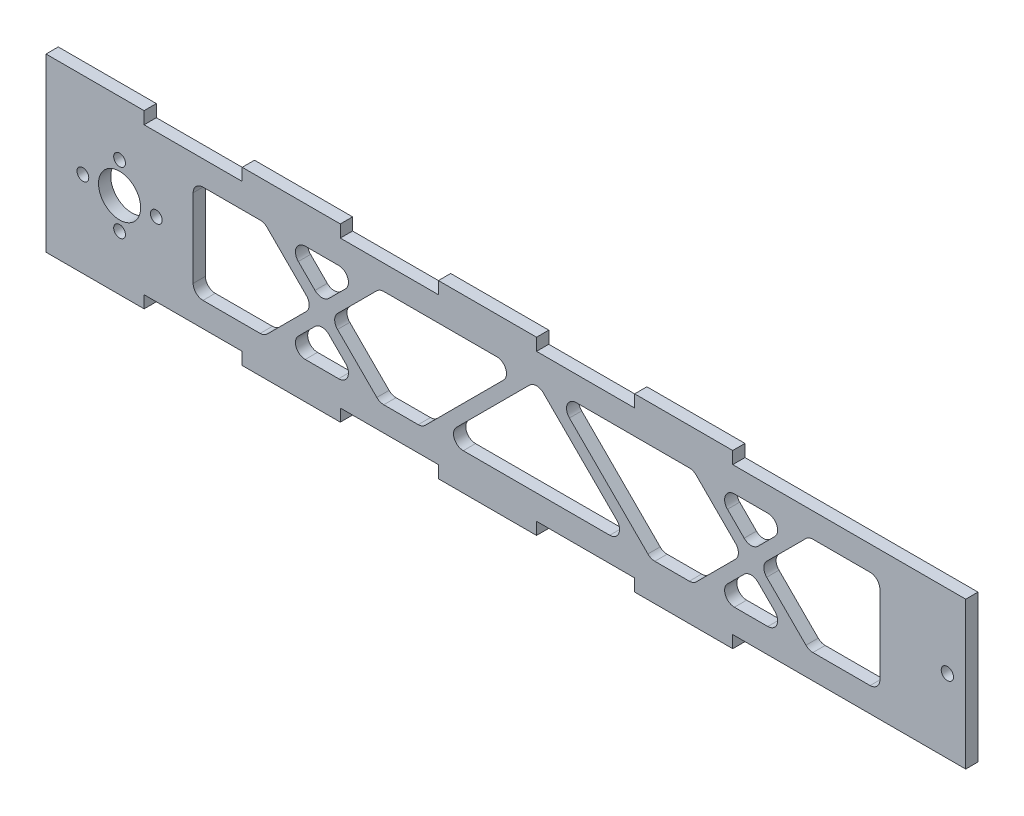
from build123d import *

# Parameters (mm, degrees)
SKETCH1_R           = 1.524
SKETCH1_R_2         = 1.5875
SKETCH1_R_3         = 5.461
BOSS_EXTRUDE1_DEPTH = 3.175


with BuildPart() as part:
    # Sketch1 → Boss-Extrude1 (new body)
    with BuildSketch(Plane.XY):
        Polygon((-24.889290425, 17.419992315), (0.510709575, 17.419992315), (0.510709575, 14.244992315), (25.910709575, 14.244992315), (25.910709575, 17.419992315), (51.310709575, 17.419992315), (51.310709575, 14.244992315), (76.710709575, 14.244992315), (76.710709575, 17.419992315), (102.110709575, 17.419992315), (102.110709575, 14.244992315), (152.910709575, 14.244992315), (162.435709575, 14.244992315), (162.435709575, -23.855007685), (102.110709575, -23.855007685), (102.110709575, -27.030007685), (76.710709575, -27.030007685), (76.710709575, -23.855007685), (51.310709575, -23.855007685), (51.310709575, -27.030007685), (25.910709575, -27.030007685), (25.910709575, -23.855007685), (0.510709575, -23.855007685), (0.510709575, -27.030007685), (-24.889290425, -27.030007685), (-24.889290425, -23.855007685), (-50.289290425, -23.855007685), (-50.289290425, -27.030007685), (-75.689290425, -27.030007685), (-75.689290425, 17.419992315), (-50.289290425, 17.419992315), (-50.289290425, 14.244992315), (-24.889290425, 14.244992315), align=None)
        with Locations((-47.139690425, -4.805007685)):
            Circle(SKETCH1_R, mode=Mode.SUBTRACT)
        with Locations((-56.639290425, -12.806007685)):
            Circle(SKETCH1_R, mode=Mode.SUBTRACT)
        with Locations((-56.639290425, 3.195992315)):
            Circle(SKETCH1_R, mode=Mode.SUBTRACT)
        with Locations((-66.138890425, -4.805007685)):
            Circle(SKETCH1_R, mode=Mode.SUBTRACT)
        with Locations((157.673209575, -4.805007685)):
            Circle(SKETCH1_R_2, mode=Mode.SUBTRACT)
        with Locations((-56.639290425, -4.805007685)):
            Circle(SKETCH1_R_3, mode=Mode.SUBTRACT)
        with BuildLine():
            Line((-2.448912015, -0.76389243), (1.873921506, 3.558941091))
            ThreePointArc((1.873921506, 3.558941091), (2.424524294, 6.327008233), (0.077870282, 7.894992315))
            Line((0.077870282, 7.894992315), (-8.567796761, 7.894992315))
            ThreePointArc((-8.567796761, 7.894992315), (-10.914450773, 6.327008233), (-10.363847985, 3.558941091))
            Line((-10.363847985, 3.558941091), (-6.041014464, -0.76389243))
            ThreePointArc((-6.041014464, -0.76389243), (-4.244963239, -1.507841206), (-2.448912015, -0.76389243))
        make_face(mode=Mode.SUBTRACT)
        with BuildLine():
            Line((-8.567796761, -17.505007685), (0.077870282, -17.505007685))
            ThreePointArc((0.077870282, -17.505007685), (2.424524294, -15.937023603), (1.873921506, -13.168956461))
            Line((1.873921506, -13.168956461), (-2.448912015, -8.846122939))
            ThreePointArc((-2.448912015, -8.846122939), (-4.244963239, -8.102174164), (-6.041014464, -8.846122939))
            Line((-6.041014464, -8.846122939), (-10.363847985, -13.168956461))
            ThreePointArc((-10.363847985, -13.168956461), (-10.914450773, -15.937023603), (-8.567796761, -17.505007685))
        make_face(mode=Mode.SUBTRACT)
        with BuildLine():
            Line((-37.589290425, 5.354992315), (-37.589290425, -14.965007685))
            ThreePointArc((-37.589290425, -14.965007685), (-36.845341649, -16.761058909), (-35.049290425, -17.505007685))
            Line((-35.049290425, -17.505007685), (-20.242129718, -17.505007685))
            ThreePointArc((-20.242129718, -17.505007685), (-19.2701138, -17.311661697), (-18.446078494, -16.761058909))
            Line((-18.446078494, -16.761058909), (-8.286078494, -6.601058909))
            ThreePointArc((-8.286078494, -6.601058909), (-7.542129718, -4.805007685), (-8.286078494, -3.008956461))
            Line((-8.286078494, -3.008956461), (-18.446078494, 7.151043539))
            ThreePointArc((-18.446078494, 7.151043539), (-19.2701138, 7.701646328), (-20.242129718, 7.894992315))
            Line((-20.242129718, 7.894992315), (-35.049290425, 7.894992315))
            ThreePointArc((-35.049290425, 7.894992315), (-36.845341649, 7.151043539), (-37.589290425, 5.354992315))
        make_face(mode=Mode.SUBTRACT)
        with BuildLine():
            Line((9.956152015, 7.151043539), (-0.203847985, -3.008956461))
            ThreePointArc((-0.203847985, -3.008956461), (-0.947796761, -4.805007685), (-0.203847985, -6.601058909))
            Line((-0.203847985, -6.601058909), (9.956152015, -16.761058909))
            ThreePointArc((9.956152015, -16.761058909), (10.780187321, -17.311661697), (11.752203239, -17.505007685))
            Line((11.752203239, -17.505007685), (20.677590576, -17.505007685))
            ThreePointArc((20.677590576, -17.505007685), (21.649606495, -17.311661697), (22.473641801, -16.761058909))
            Line((22.473641801, -16.761058909), (42.793641801, 3.558941091))
            ThreePointArc((42.793641801, 3.558941091), (43.344244589, 6.327008233), (40.997590576, 7.894992315))
            Line((40.997590576, 7.894992315), (11.752203239, 7.894992315))
            ThreePointArc((11.752203239, 7.894992315), (10.780187321, 7.701646328), (9.956152015, 7.151043539))
        make_face(mode=Mode.SUBTRACT)
        with BuildLine():
            Line((121.067497644, -16.761058909), (110.907497644, -6.601058909))
            ThreePointArc((110.907497644, -6.601058909), (110.163548868, -4.805007685), (110.907497644, -3.008956461))
            Line((110.907497644, -3.008956461), (121.067497644, 7.151043539))
            ThreePointArc((121.067497644, 7.151043539), (121.89153295, 7.701646328), (122.863548868, 7.894992315))
            Line((122.863548868, 7.894992315), (137.670709575, 7.894992315))
            ThreePointArc((137.670709575, 7.894992315), (139.466760799, 7.151043539), (140.210709575, 5.354992315))
            Line((140.210709575, 5.354992315), (140.210709575, -14.965007685))
            ThreePointArc((140.210709575, -14.965007685), (139.466760799, -16.761058909), (137.670709575, -17.505007685))
            Line((137.670709575, -17.505007685), (122.863548868, -17.505007685))
            ThreePointArc((122.863548868, -17.505007685), (121.89153295, -17.311661697), (121.067497644, -16.761058909))
        make_face(mode=Mode.SUBTRACT)
        with BuildLine():
            Line((90.869215911, 7.894992315), (61.623828574, 7.894992315))
            ThreePointArc((61.623828574, 7.894992315), (59.277174561, 6.327008233), (59.82777735, 3.558941091))
            Line((59.82777735, 3.558941091), (80.14777735, -16.761058909))
            ThreePointArc((80.14777735, -16.761058909), (80.971812656, -17.311661697), (81.943828574, -17.505007685))
            Line((81.943828574, -17.505007685), (90.869215911, -17.505007685))
            ThreePointArc((90.869215911, -17.505007685), (91.841231829, -17.311661697), (92.665267135, -16.761058909))
            Line((92.665267135, -16.761058909), (102.825267135, -6.601058909))
            ThreePointArc((102.825267135, -6.601058909), (103.569215911, -4.805007685), (102.825267135, -3.008956461))
            Line((102.825267135, -3.008956461), (92.665267135, 7.151043539))
            ThreePointArc((92.665267135, 7.151043539), (91.841231829, 7.701646328), (90.869215911, 7.894992315))
        make_face(mode=Mode.SUBTRACT)
        with BuildLine():
            Line((111.189215911, -17.505007685), (102.543548868, -17.505007685))
            ThreePointArc((102.543548868, -17.505007685), (100.196894856, -15.937023603), (100.747497644, -13.168956461))
            Line((100.747497644, -13.168956461), (105.070331165, -8.846122939))
            ThreePointArc((105.070331165, -8.846122939), (106.86638239, -8.102174164), (108.662433614, -8.846122939))
            Line((108.662433614, -8.846122939), (112.985267135, -13.168956461))
            ThreePointArc((112.985267135, -13.168956461), (113.535869924, -15.937023603), (111.189215911, -17.505007685))
        make_face(mode=Mode.SUBTRACT)
        with BuildLine():
            Line((105.070331165, -0.76389243), (100.747497644, 3.558941091))
            ThreePointArc((100.747497644, 3.558941091), (100.196894856, 6.327008233), (102.543548868, 7.894992315))
            Line((102.543548868, 7.894992315), (111.189215911, 7.894992315))
            ThreePointArc((111.189215911, 7.894992315), (113.535869924, 6.327008233), (112.985267135, 3.558941091))
            Line((112.985267135, 3.558941091), (108.662433614, -0.76389243))
            ThreePointArc((108.662433614, -0.76389243), (106.86638239, -1.507841206), (105.070331165, -0.76389243))
        make_face(mode=Mode.SUBTRACT)
        with BuildLine():
            Line((67.742713319, -8.846122939), (72.065546841, -13.168956461))
            ThreePointArc((72.065546841, -13.168956461), (72.616149629, -15.937023603), (70.269495616, -17.505007685))
            Line((70.269495616, -17.505007685), (32.351923534, -17.505007685))
            ThreePointArc((32.351923534, -17.505007685), (30.005269521, -15.937023603), (30.55587231, -13.168956461))
            Line((30.55587231, -13.168956461), (49.514658351, 5.789829581))
            ThreePointArc((49.514658351, 5.789829581), (51.310709575, 6.533778356), (53.106760799, 5.789829581))
            Line((53.106760799, 5.789829581), (67.742713319, -8.846122939))
        make_face(mode=Mode.SUBTRACT)
    extrude(amount=BOSS_EXTRUDE1_DEPTH)


solid = part.part
